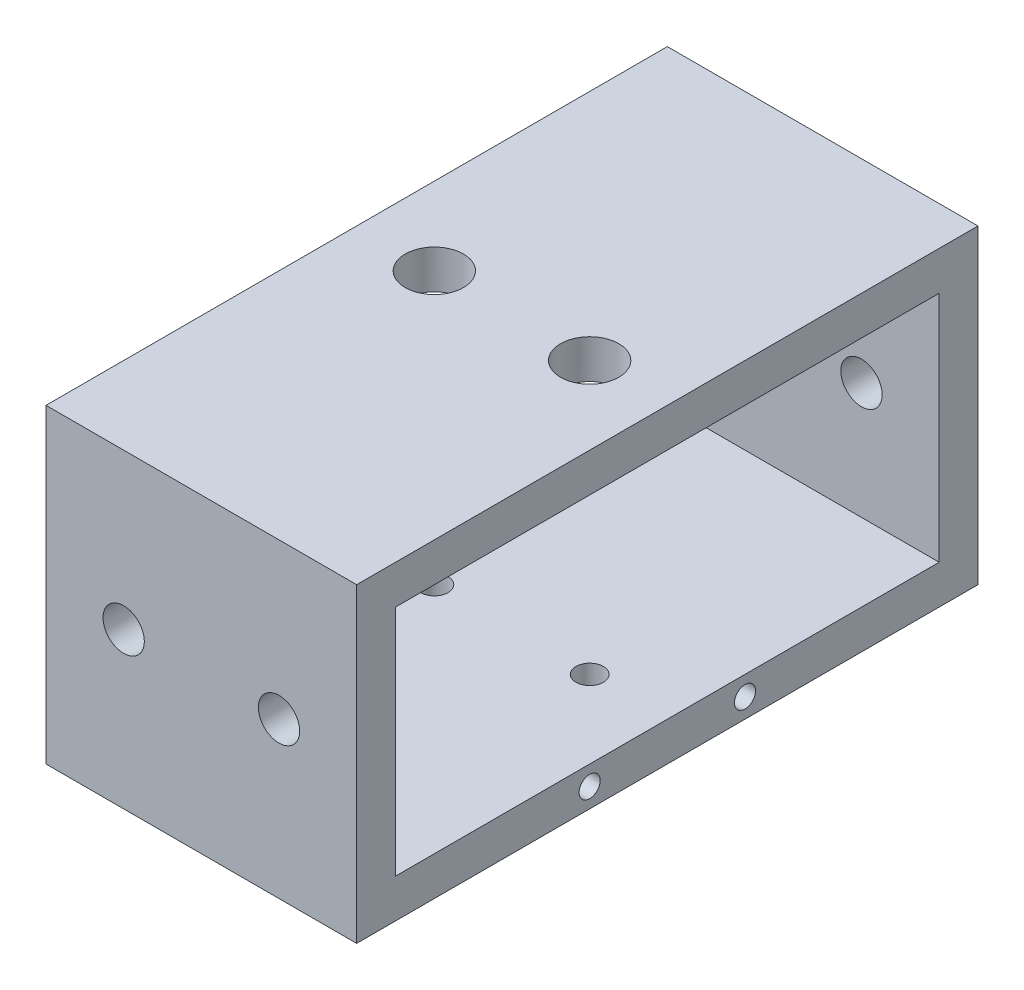
from build123d import *

# Parameters (mm, degrees)
SKETCH2_W                        = 101.6
SKETCH2_H                        = 50.8
SKETCH2_W_2                      = 88.9
SKETCH2_H_2                      = 38.1
BOSS_EXTRUDE1_DEPTH              = 25.4
F_1_4_CLEARANCE_HOLE1_D          = 6.7564
F_8_CLEARANCE_HOLE1_D            = 4.4958
F_8_CLEARANCE_HOLE1_DEPTH        = 6.35
F_3_8_0_375_DIAMETER_HOLE1_D     = 9.525
F_3_8_0_375_DIAMETER_HOLE1_DEPTH = 6.35
F_8_32_TAPPED_HOLE1_D            = 3.4544
F_8_32_TAPPED_HOLE1_DEPTH        = 12.7
F_8_32_TAPPED_HOLE1_TIP          = 1.037806461


with BuildPart() as part:
    # Sketch2 → Boss-Extrude1 (new body, symmetric)
    with BuildSketch(Plane(origin=(0, 0, 0), x_dir=(0, 0, -1), z_dir=(1, 0, 0))):
        Rectangle(SKETCH2_W, SKETCH2_H)
        Rectangle(SKETCH2_W_2, SKETCH2_H_2, mode=Mode.SUBTRACT)
    extrude(amount=BOSS_EXTRUDE1_DEPTH, both=True)

    # 1/4 Clearance Hole1 (through all)
    with Locations(Plane.XY.offset(50.8)):
        with Locations((-12.7, 0), (12.7, 0)):
            Hole(F_1_4_CLEARANCE_HOLE1_D / 2)

    # #8 Clearance Hole1
    with Locations(Plane(origin=(0, -19.05, 0), x_dir=(1, 0, 0), z_dir=(0, 1, 0))):
        with Locations((12.7, 0)):
            f_8_clearance_hole1 = Hole(F_8_CLEARANCE_HOLE1_D / 2, depth=F_8_CLEARANCE_HOLE1_DEPTH)

    # Mirror1: #8 Clearance Hole1 across plane
    add(f_8_clearance_hole1.mirror(Plane(origin=(0, 0, 0), x_dir=(0, 0, 1), z_dir=(1, 0, 0))), mode=Mode.SUBTRACT)

    # 3/8 (0.375) Diameter Hole1
    with Locations(Plane(origin=(0, 25.4, 0), x_dir=(1, 0, 0), z_dir=(0, 1, 0))):
        with Locations((-12.7, 0), (12.7, 0)):
            Hole(F_3_8_0_375_DIAMETER_HOLE1_D / 2, depth=F_3_8_0_375_DIAMETER_HOLE1_DEPTH)

    # #8-32 Tapped Hole1
    with Locations(Plane(origin=(25.4, 0, 0), x_dir=(0, 0, 1), z_dir=(1, 0, 0))):
        with Locations((-12.7, 22.225), (12.7, 22.225)):
            Hole(F_8_32_TAPPED_HOLE1_D / 2, depth=F_8_32_TAPPED_HOLE1_DEPTH)
            with Locations((0, 0, -(F_8_32_TAPPED_HOLE1_DEPTH + F_8_32_TAPPED_HOLE1_TIP / 2))):  # 118° drill point
                Cone(0, F_8_32_TAPPED_HOLE1_D / 2, F_8_32_TAPPED_HOLE1_TIP, mode=Mode.SUBTRACT)


solid = part.part
